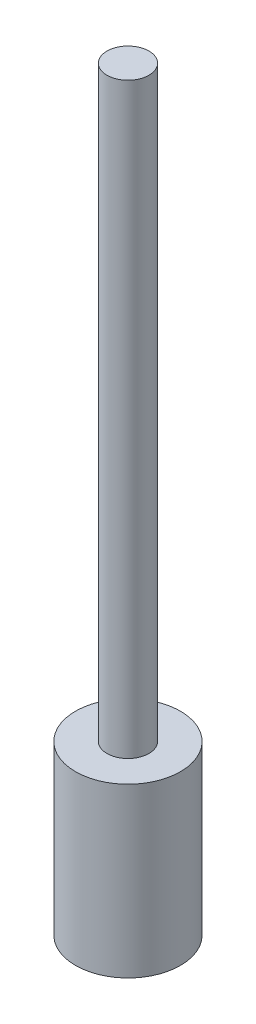
from build123d import *

# Parameters (mm, degrees)
SKETCH1_R           = 12.5
BOSS_EXTRUDE1_DEPTH = 40
SKETCH2_R           = 5
BOSS_EXTRUDE2_DEPTH = 140


with BuildPart() as part:
    # Sketch1 → Boss-Extrude1 (new body)
    with BuildSketch(Plane(origin=(0, 0, 0), x_dir=(1, 0, 0), z_dir=(0, 1, 0))):
        Circle(SKETCH1_R)
    extrude(amount=BOSS_EXTRUDE1_DEPTH)

    # Sketch2 → Boss-Extrude2 (add)
    with BuildSketch(Plane(origin=(0, 40, 0), x_dir=(1, 0, 0), z_dir=(0, 1, 0))):
        Circle(SKETCH2_R)
    extrude(amount=BOSS_EXTRUDE2_DEPTH)


solid = part.part
